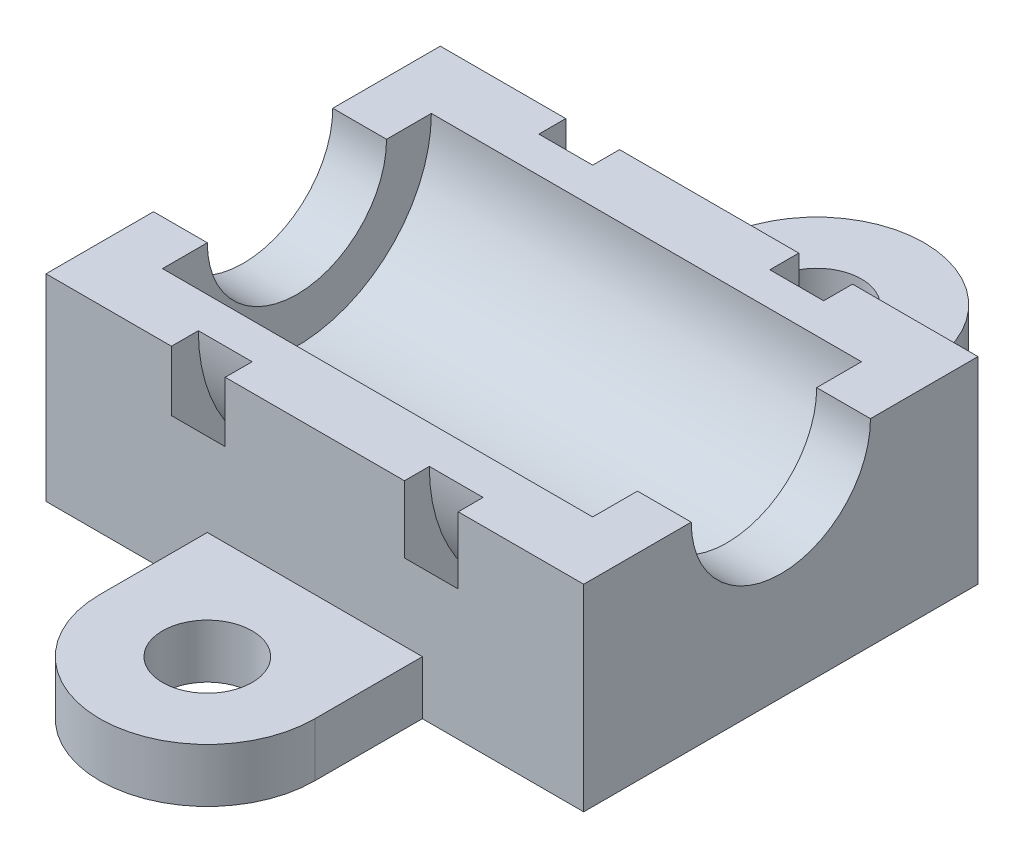
from build123d import *

# Parameters (mm, degrees)
CROQUIS1_W              = 30
CROQUIS1_H              = 22
SALIENTE_EXTRUIR1_DEPTH = 11
CROQUIS2_R              = 2.5
SALIENTE_EXTRUIR2_DEPTH = 3
CROQUIS3_R              = 5
CORTAR_EXTRUIR1_DEPTH   = 31
CROQUIS4_R              = 11.5
CROQUIS4_R_2            = 9.5
CORTAR_EXTRUIR13_DEPTH  = 3
CROQUIS6_R              = 11.5
CROQUIS6_R_2            = 9.5
CORTAR_EXTRUIR14_DEPTH  = 3
CROQUIS7_R              = 7.5
CORTAR_EXTRUIR15_DEPTH  = 24


with BuildPart() as part:
    # Croquis1 → Saliente-Extruir1 (new body)
    with BuildSketch(Plane(origin=(0, 0, 0), x_dir=(1, 0, 0), z_dir=(0, 1, 0))):
        with Locations((15, 11)):
            Rectangle(CROQUIS1_W, CROQUIS1_H)
    extrude(amount=SALIENTE_EXTRUIR1_DEPTH)

    # Croquis2 → Saliente-Extruir2 (add)
    with BuildSketch(Plane.XZ):
        with BuildLine():
            Line((21, 6), (21, 0))
            Line((21, 0), (9, 0))
            Line((9, 0), (9, 6))
            ThreePointArc((9, 6), (15, 12), (21, 6))
        make_face()
        with Locations((15, 6)):
            Circle(CROQUIS2_R, mode=Mode.SUBTRACT)
        with BuildLine():
            Line((9, -22), (9, -28))
            ThreePointArc((9, -28), (15, -34), (21, -28))
            Line((21, -28), (21, -22))
            Line((21, -22), (9, -22))
        make_face()
        with Locations((15, -28)):
            Circle(CROQUIS2_R, mode=Mode.SUBTRACT)
    extrude(amount=-SALIENTE_EXTRUIR2_DEPTH)

    # Croquis3 → Cortar-Extruir1 (cut, through all)
    with BuildSketch(Plane.ZY):
        with Locations((-11, 11)):
            Circle(CROQUIS3_R)
    extrude(amount=-CORTAR_EXTRUIR1_DEPTH, mode=Mode.SUBTRACT)

    # Croquis4 → Cortar-Extruir13 (cut)
    with BuildSketch(Plane.ZY.offset(-10)):
        with Locations((-11, 11)):
            Circle(CROQUIS4_R)
        with Locations((-11, 11)):
            Circle(CROQUIS4_R_2, mode=Mode.SUBTRACT)
    extrude(amount=CORTAR_EXTRUIR13_DEPTH, mode=Mode.SUBTRACT)

    # Croquis6 → Cortar-Extruir14 (cut)
    with BuildSketch(Plane(origin=(20, 0, 0), x_dir=(0, 0, -1), z_dir=(1, 0, 0))):
        with Locations((10.887185848, 10.972715561)):
            Circle(CROQUIS6_R)
        with Locations((10.887185848, 10.972715561)):
            Circle(CROQUIS6_R_2, mode=Mode.SUBTRACT)
    extrude(amount=CORTAR_EXTRUIR14_DEPTH, mode=Mode.SUBTRACT)

    # Croquis7 → Cortar-Extruir15 (cut)
    with BuildSketch(Plane.ZY.offset(-3)):
        with Locations((-11, 11)):
            Circle(CROQUIS7_R)
    extrude(amount=-CORTAR_EXTRUIR15_DEPTH, mode=Mode.SUBTRACT)


solid = part.part
